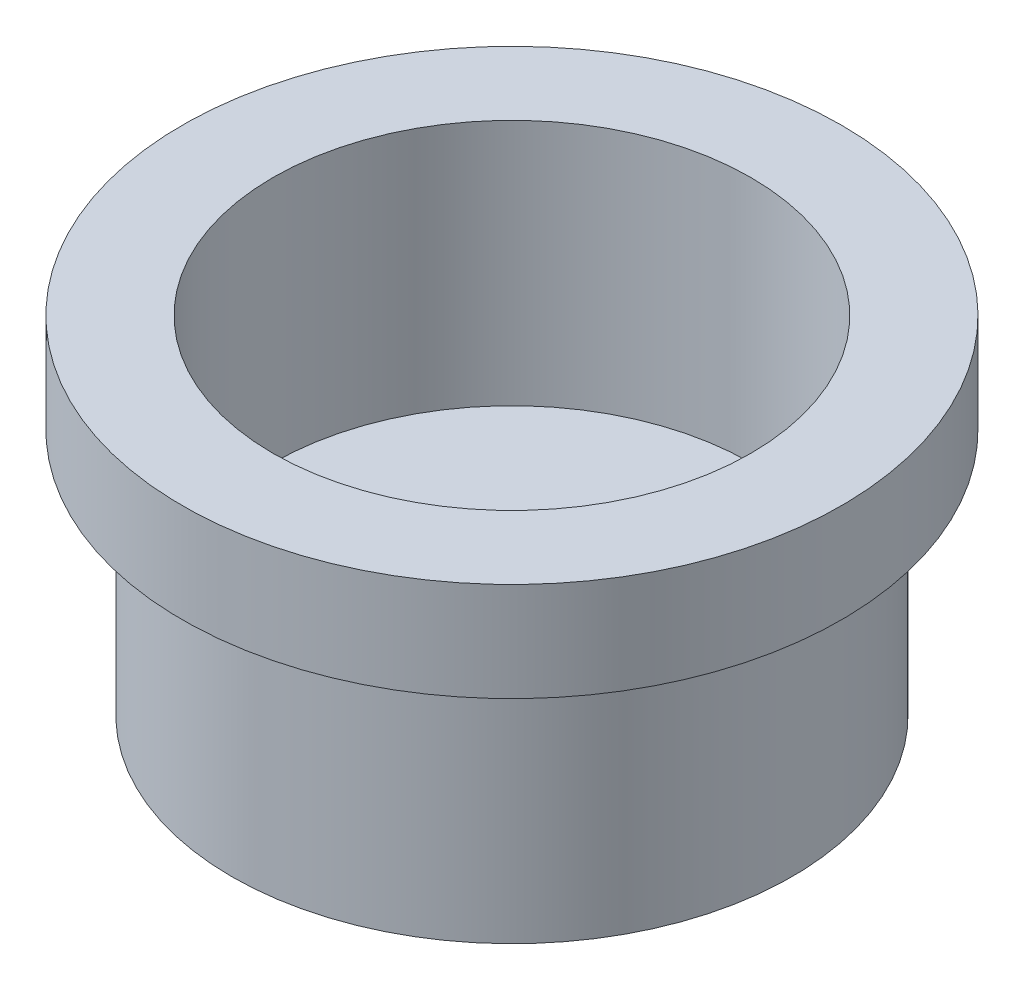
from build123d import *


with BuildPart() as part:
    # 草图1 → 旋转1 (revolve)
    with BuildSketch(Plane.XY):
        Polygon((-2.5, 0), (-2.5, 8), (-4.7, 8), (-4.7, 12), (-14.5, 12), (-14.5, 27), (-20, 27), (-20, 21), (-17, 21), (-17, 6), (-6.5, 6), (-6.5, 5), (-4.5, 5), (-4.5, 0), align=None)
    revolve(axis=Axis((0, 0, 0), (0, 1, 0)))


solid = part.part
